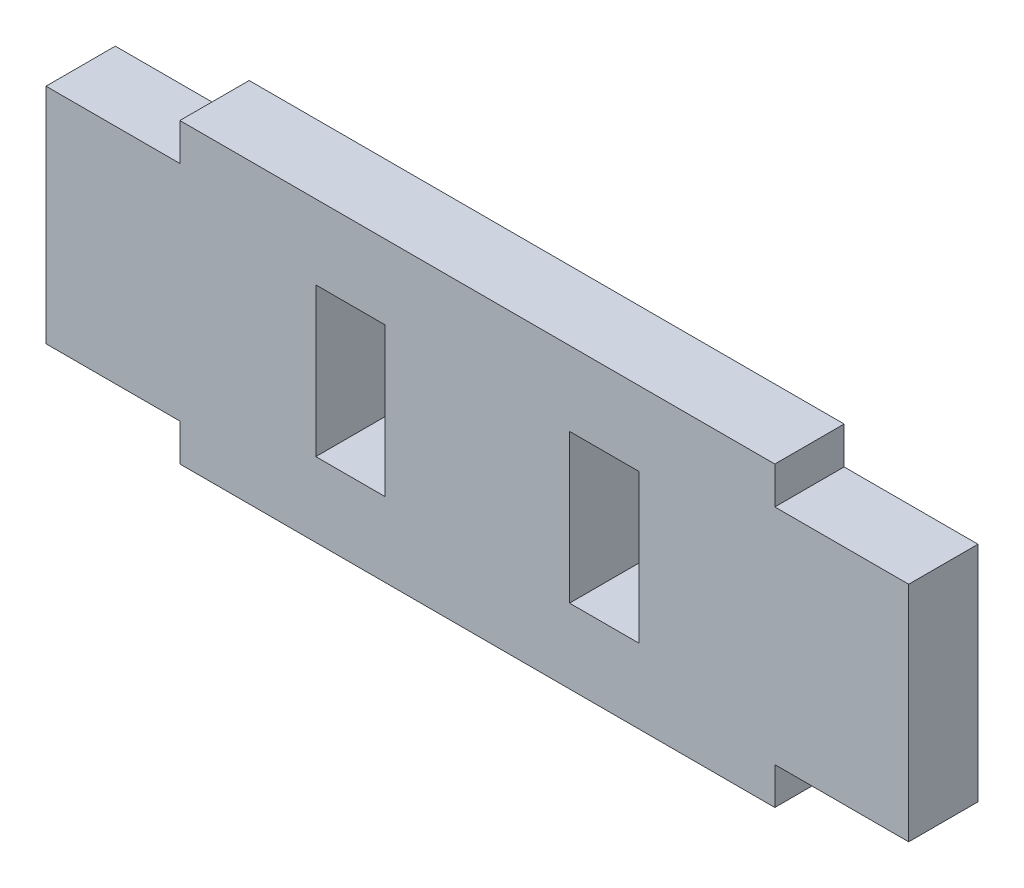
from build123d import *

# Parameters (mm, degrees)
SKETCH3_W           = 2.9591
SKETCH3_H           = 6.35
BOSS_EXTRUDE1_DEPTH = 1.47955


with BuildPart() as part:
    # Sketch3 → Boss-Extrude1 (new body, symmetric)
    with BuildSketch(Plane.XY):
        Polygon((-12.7, 6.35), (12.7, 6.35), (12.7, 4.7625), (18.415, 4.7625), (18.415, -4.7625), (12.7, -4.7625), (12.7, -6.35), (-12.7, -6.35), (-12.7, -4.7625), (-18.415, -4.7625), (-18.415, 4.7625), (-12.7, 4.7625), align=None)
        with Locations((-5.41655, 0)):
            Rectangle(SKETCH3_W, SKETCH3_H, mode=Mode.SUBTRACT)
        with Locations((5.41655, 0)):
            Rectangle(SKETCH3_W, SKETCH3_H, mode=Mode.SUBTRACT)
    extrude(amount=BOSS_EXTRUDE1_DEPTH, both=True)


solid = part.part
